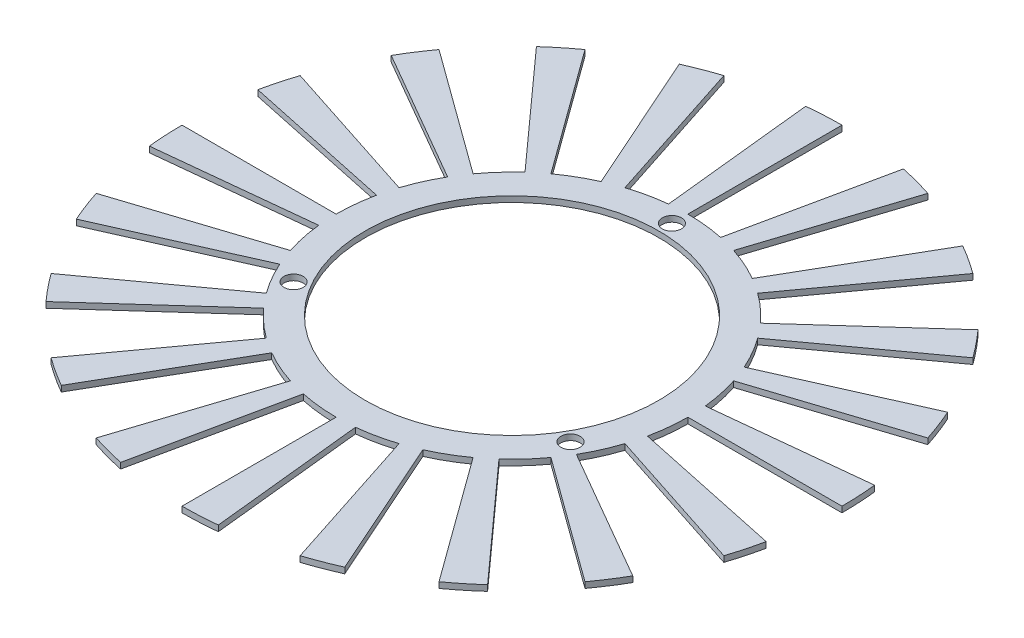
from build123d import *

# Parameters (mm, degrees)
SKETCH1_R           = 30.25
SKETCH1_R_2         = 25.25
EXTRUDE_THIN1_DEPTH = 1
SKETCH2_R           = 1.65
CUT_EXTRUDE3_DEPTH  = 10
BOSS_EXTRUDE1_DEPTH = 1


with BuildPart() as part:
    # Sketch1 → Extrude-Thin1 (new body)
    with BuildSketch(Plane(origin=(0, 0, 0), x_dir=(1, 0, 0), z_dir=(0, 1, 0))):
        Circle(SKETCH1_R)
        Circle(SKETCH1_R_2, mode=Mode.SUBTRACT)
    extrude(amount=-EXTRUDE_THIN1_DEPTH)

    # Sketch2 → Cut-Extrude3 (cut)
    with BuildSketch(Plane(origin=(0, 0, 0), x_dir=(1, 0, 0), z_dir=(0, 1, 0))):
        with Locations((0, 27.5)):
            Circle(SKETCH2_R)
        with Locations((23.815698604, -13.75)):
            Circle(SKETCH2_R)
        with Locations((-23.815698604, -13.75)):
            Circle(SKETCH2_R)
    extrude(amount=-CUT_EXTRUDE3_DEPTH, mode=Mode.SUBTRACT)

    # Sketch5 → Boss-Extrude1 (add)
    with BuildSketch(Plane.XZ.offset(1)):
        with BuildLine():
            Line((0, 56.75), (0, 30.25))
            ThreePointArc((0, 30.25), (1.583162676, 30.208543426), (3.161986014, 30.084287335))
            Line((3.161986014, 30.084287335), (5.93199029, 56.439117562))
            ThreePointArc((5.93199029, 56.439117562), (2.970065517, 56.672226097), (0, 56.75))
        make_face()
        with BuildLine():
            Line((17.536714431, 53.9724573), (9.34776408, 28.769459618))
            ThreePointArc((9.34776408, 28.769459618), (10.840630474, 28.240807902), (12.303783453, 27.634750094))
            Line((12.303783453, 27.634750094), (23.082304495, 51.843704721))
            ThreePointArc((23.082304495, 51.843704721), (20.337381137, 52.980689204), (17.536714431, 53.9724573))
        make_face()
        with BuildLine():
            Line((33.356813068, 45.911714431), (17.780503882, 24.47276408))
            ThreePointArc((17.780503882, 24.47276408), (19.036941829, 23.508665334), (20.241200842, 22.480130971))
            Line((20.241200842, 22.480130971), (37.973161911, 42.173468846))
            ThreePointArc((37.973161911, 42.173468846), (35.713932192, 44.103033313), (33.356813068, 45.911714431))
        make_face()
        with BuildLine():
            Line((45.911714431, 33.356813068), (24.47276408, 17.780503882))
            ThreePointArc((24.47276408, 17.780503882), (25.36978468, 16.475330809), (26.197268464, 15.125))
            Line((26.197268464, 15.125), (49.146941665, 28.375))
            ThreePointArc((49.146941665, 28.375), (47.594554731, 30.908265237), (45.911714431, 33.356813068))
        make_face()
        with BuildLine():
            Line((53.9724573, 17.536714431), (28.769459618, 9.34776408))
            ThreePointArc((28.769459618, 9.34776408), (29.219256245, 7.829276114), (29.588964922, 6.289328647))
            Line((29.588964922, 6.289328647), (55.509876342, 11.798988454))
            ThreePointArc((55.509876342, 11.798988454), (54.816290642, 14.68798081), (53.9724573, 17.536714431))
        make_face()
        with BuildLine():
            Line((56.75, 0), (30.25, 0))
            ThreePointArc((30.25, 0), (30.208543426, -1.583162676), (30.084287335, -3.161986014))
            Line((30.084287335, -3.161986014), (56.439117562, -5.93199029))
            ThreePointArc((56.439117562, -5.93199029), (56.672226097, -2.970065517), (56.75, 0))
        make_face()
        with BuildLine():
            Line((53.9724573, -17.536714431), (28.769459618, -9.34776408))
            ThreePointArc((28.769459618, -9.34776408), (28.240807902, -10.840630474), (27.634750094, -12.303783453))
            Line((27.634750094, -12.303783453), (51.843704721, -23.082304495))
            ThreePointArc((51.843704721, -23.082304495), (52.980689204, -20.337381137), (53.9724573, -17.536714431))
        make_face()
        with BuildLine():
            Line((45.911714431, -33.356813068), (24.47276408, -17.780503882))
            ThreePointArc((24.47276408, -17.780503882), (23.508665334, -19.036941829), (22.480130971, -20.241200842))
            Line((22.480130971, -20.241200842), (42.173468846, -37.973161911))
            ThreePointArc((42.173468846, -37.973161911), (44.103033313, -35.713932192), (45.911714431, -33.356813068))
        make_face()
        with BuildLine():
            Line((33.356813068, -45.911714431), (17.780503882, -24.47276408))
            ThreePointArc((17.780503882, -24.47276408), (16.475330809, -25.36978468), (15.125, -26.197268464))
            Line((15.125, -26.197268464), (28.375, -49.146941665))
            ThreePointArc((28.375, -49.146941665), (30.908265237, -47.594554731), (33.356813068, -45.911714431))
        make_face()
        with BuildLine():
            Line((17.536714431, -53.9724573), (9.34776408, -28.769459618))
            ThreePointArc((9.34776408, -28.769459618), (7.829276114, -29.219256245), (6.289328647, -29.588964922))
            Line((6.289328647, -29.588964922), (11.798988454, -55.509876342))
            ThreePointArc((11.798988454, -55.509876342), (14.68798081, -54.816290642), (17.536714431, -53.9724573))
        make_face()
        with BuildLine():
            Line((0, -56.75), (0, -30.25))
            ThreePointArc((0, -30.25), (-1.583162676, -30.208543426), (-3.161986014, -30.084287335))
            Line((-3.161986014, -30.084287335), (-5.93199029, -56.439117562))
            ThreePointArc((-5.93199029, -56.439117562), (-2.970065517, -56.672226097), (0, -56.75))
        make_face()
        with BuildLine():
            Line((-17.536714431, -53.9724573), (-9.34776408, -28.769459618))
            ThreePointArc((-9.34776408, -28.769459618), (-10.840630474, -28.240807902), (-12.303783453, -27.634750094))
            Line((-12.303783453, -27.634750094), (-23.082304495, -51.843704721))
            ThreePointArc((-23.082304495, -51.843704721), (-20.337381137, -52.980689204), (-17.536714431, -53.9724573))
        make_face()
        with BuildLine():
            Line((-33.356813068, -45.911714431), (-17.780503882, -24.47276408))
            ThreePointArc((-17.780503882, -24.47276408), (-19.036941829, -23.508665334), (-20.241200842, -22.480130971))
            Line((-20.241200842, -22.480130971), (-37.973161911, -42.173468846))
            ThreePointArc((-37.973161911, -42.173468846), (-35.713932192, -44.103033313), (-33.356813068, -45.911714431))
        make_face()
        with BuildLine():
            Line((-45.911714431, -33.356813068), (-24.47276408, -17.780503882))
            ThreePointArc((-24.47276408, -17.780503882), (-25.36978468, -16.475330809), (-26.197268464, -15.125))
            Line((-26.197268464, -15.125), (-49.146941665, -28.375))
            ThreePointArc((-49.146941665, -28.375), (-47.594554731, -30.908265237), (-45.911714431, -33.356813068))
        make_face()
        with BuildLine():
            Line((-53.9724573, -17.536714431), (-28.769459618, -9.34776408))
            ThreePointArc((-28.769459618, -9.34776408), (-29.219256245, -7.829276114), (-29.588964922, -6.289328647))
            Line((-29.588964922, -6.289328647), (-55.509876342, -11.798988454))
            ThreePointArc((-55.509876342, -11.798988454), (-54.816290642, -14.68798081), (-53.9724573, -17.536714431))
        make_face()
        with BuildLine():
            Line((-56.75, 0), (-30.25, 0))
            ThreePointArc((-30.25, 0), (-30.208543426, 1.583162676), (-30.084287335, 3.161986014))
            Line((-30.084287335, 3.161986014), (-56.439117562, 5.93199029))
            ThreePointArc((-56.439117562, 5.93199029), (-56.672226097, 2.970065517), (-56.75, 0))
        make_face()
        with BuildLine():
            Line((-53.9724573, 17.536714431), (-28.769459618, 9.34776408))
            ThreePointArc((-28.769459618, 9.34776408), (-28.240807902, 10.840630474), (-27.634750094, 12.303783453))
            Line((-27.634750094, 12.303783453), (-51.843704721, 23.082304495))
            ThreePointArc((-51.843704721, 23.082304495), (-52.980689204, 20.337381137), (-53.9724573, 17.536714431))
        make_face()
        with BuildLine():
            Line((-45.911714431, 33.356813068), (-24.47276408, 17.780503882))
            ThreePointArc((-24.47276408, 17.780503882), (-23.508665334, 19.036941829), (-22.480130971, 20.241200842))
            Line((-22.480130971, 20.241200842), (-42.173468846, 37.973161911))
            ThreePointArc((-42.173468846, 37.973161911), (-44.103033313, 35.713932192), (-45.911714431, 33.356813068))
        make_face()
        with BuildLine():
            Line((-33.356813068, 45.911714431), (-17.780503882, 24.47276408))
            ThreePointArc((-17.780503882, 24.47276408), (-16.475330809, 25.36978468), (-15.125, 26.197268464))
            Line((-15.125, 26.197268464), (-28.375, 49.146941665))
            ThreePointArc((-28.375, 49.146941665), (-30.908265237, 47.594554731), (-33.356813068, 45.911714431))
        make_face()
        with BuildLine():
            Line((-17.536714431, 53.9724573), (-9.34776408, 28.769459618))
            ThreePointArc((-9.34776408, 28.769459618), (-7.829276114, 29.219256245), (-6.289328647, 29.588964922))
            Line((-6.289328647, 29.588964922), (-11.798988454, 55.509876342))
            ThreePointArc((-11.798988454, 55.509876342), (-14.68798081, 54.816290642), (-17.536714431, 53.9724573))
        make_face()
    extrude(amount=-BOSS_EXTRUDE1_DEPTH)


solid = part.part
